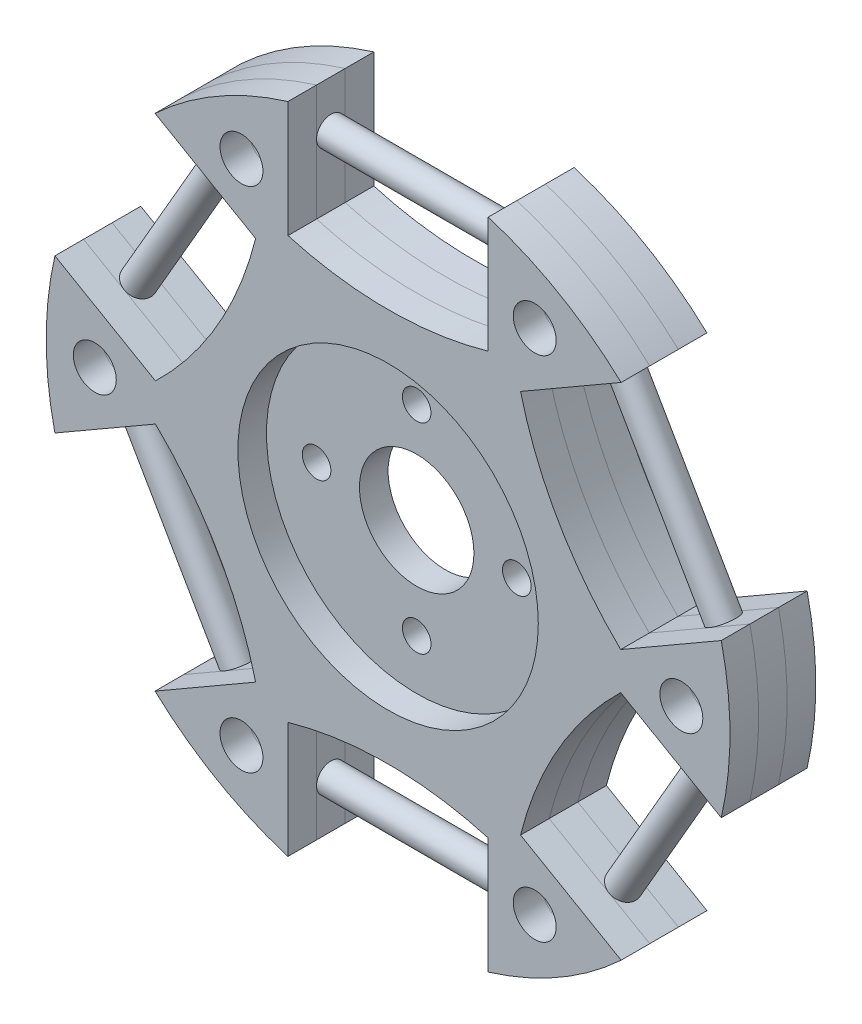
from build123d import *

# Parameters (mm, degrees)
SKETCH_1_R               = 25.4
SKETCH_1_R_2             = 10.5
EXTRUDE_1_DEPTH          = 2
SKETCH_2_R               = 25.4
SKETCH_2_R_2             = 4
EXTRUDE_2_DEPTH          = 2
SKETCH_3_R               = 25.4
SKETCH_3_R_2             = 10.5
EXTRUDE_3_DEPTH          = 2
CUT_EXTRUDE_1_DEPTH      = 20.5
SKETCH_5_R               = 1.5
CUT_EXTRUDE_2_DEPTH      = 20.5
SKETCH_6_R               = 1
EXTRUDE_4_DEPTH          = 14
PATTERN_CIRCULAR_1_COUNT = 6
SKETCH_7_R               = 1
CUT_EXTRUDE_3_DEPTH      = 14
SKETCH_8_R               = 33.9
SKETCH_8_R_2             = 23.9
CUT_EXTRUDE_1_2_DEPTH    = 10


with BuildPart() as part:
    # 草图1 → 凸台-拉伸1 (new body)
    with BuildSketch(Plane.XY):
        Circle(SKETCH_1_R)
        Circle(SKETCH_1_R_2, mode=Mode.SUBTRACT)
    extrude(amount=EXTRUDE_1_DEPTH)


with BuildPart() as body_2:
    # 草图2 → 凸台-拉伸2 (new body)
    with BuildSketch(Plane.XY.offset(2)):
        Circle(SKETCH_2_R)
        Circle(SKETCH_2_R_2, mode=Mode.SUBTRACT)
    extrude(amount=EXTRUDE_2_DEPTH)


with BuildPart() as body_3:
    # 草图3 → 凸台-拉伸3 (new body)
    with BuildSketch(Plane.XY.offset(4)):
        Circle(SKETCH_3_R)
        Circle(SKETCH_3_R_2, mode=Mode.SUBTRACT)
    extrude(amount=EXTRUDE_3_DEPTH)


with BuildPart() as cut_extrude_1_tool:
    # 草图4 → Cut-Extrude 1 (new body)
    with BuildSketch(Plane.XY.offset(6)):
        with BuildLine():
            Line((9.259682334, 13.428983857), (17.645212224, 18.270371796))
            ThreePointArc((17.645212224, 18.270371796), (21.997045256, 12.7), (24.645212224, 6.146016143))
            Line((24.645212224, 6.146016143), (16.259682334, 1.304628204))
            ThreePointArc((16.259682334, 1.304628204), (11.907849302, 6.875), (9.259682334, 13.428983857))
        make_face()
        with BuildLine():
            Line((7, 14.733612061), (7, 24.416387939))
            ThreePointArc((7, 24.416387939), (0, 25.4), (-7, 24.416387939))
            Line((-7, 24.416387939), (-7, 14.733612061))
            ThreePointArc((-7, 14.733612061), (0, 13.75), (7, 14.733612061))
        make_face()
        with BuildLine():
            Line((16.259682334, -1.304628204), (24.645212224, -6.146016143))
            ThreePointArc((24.645212224, -6.146016143), (21.997045256, -12.7), (17.645212224, -18.270371796))
            Line((17.645212224, -18.270371796), (9.259682334, -13.428983857))
            ThreePointArc((9.259682334, -13.428983857), (11.907849302, -6.875), (16.259682334, -1.304628204))
        make_face()
        with BuildLine():
            Line((7, -14.733612061), (7, -24.416387939))
            ThreePointArc((7, -24.416387939), (0, -25.4), (-7, -24.416387939))
            Line((-7, -24.416387939), (-7, -14.733612061))
            ThreePointArc((-7, -14.733612061), (0, -13.75), (7, -14.733612061))
        make_face()
        with BuildLine():
            Line((-9.259682334, -13.428983857), (-17.645212224, -18.270371796))
            ThreePointArc((-17.645212224, -18.270371796), (-21.997045256, -12.7), (-24.645212224, -6.146016143))
            Line((-24.645212224, -6.146016143), (-16.259682334, -1.304628204))
            ThreePointArc((-16.259682334, -1.304628204), (-11.907849302, -6.875), (-9.259682334, -13.428983857))
        make_face()
        with BuildLine():
            Line((-16.259682334, 1.304628204), (-24.645212224, 6.146016143))
            ThreePointArc((-24.645212224, 6.146016143), (-21.997045256, 12.7), (-17.645212224, 18.270371796))
            Line((-17.645212224, 18.270371796), (-9.259682334, 13.428983857))
            ThreePointArc((-9.259682334, 13.428983857), (-11.907849302, 6.875), (-16.259682334, 1.304628204))
        make_face()
    extrude(amount=-CUT_EXTRUDE_1_DEPTH)


with BuildPart() as part_1:
    add(part.part)

    # Cut-Extrude 1: cut by cut_extrude_1_tool
    add(cut_extrude_1_tool.part, mode=Mode.SUBTRACT)


with BuildPart() as body_2_1:
    add(body_2.part)

    # Cut-Extrude 1: cut by cut_extrude_1_tool
    add(cut_extrude_1_tool.part, mode=Mode.SUBTRACT)


with BuildPart() as body_3_1:
    add(body_3.part)

    # Cut-Extrude 1: cut by cut_extrude_1_tool
    add(cut_extrude_1_tool.part, mode=Mode.SUBTRACT)


with BuildPart() as cut_extrude_2_tool:
    # 草图5 → 切除-拉伸2 (new body)
    with BuildSketch(Plane.XY.offset(6)):
        with Locations((10.25, 17.753520778)):
            Circle(SKETCH_5_R)
        with Locations((20.5, 0)):
            Circle(SKETCH_5_R)
        with Locations((10.25, -17.753520778)):
            Circle(SKETCH_5_R)
        with Locations((-10.25, -17.753520778)):
            Circle(SKETCH_5_R)
        with Locations((-20.5, 0)):
            Circle(SKETCH_5_R)
        with Locations((-10.25, 17.753520778)):
            Circle(SKETCH_5_R)
    extrude(amount=-CUT_EXTRUDE_2_DEPTH)


with BuildPart() as part_2:
    add(part_1.part)

    # 切除-拉伸2: cut by cut_extrude_2_tool
    add(cut_extrude_2_tool.part, mode=Mode.SUBTRACT)


with BuildPart() as body_2_2:
    add(body_2_1.part)

    # 切除-拉伸2: cut by cut_extrude_2_tool
    add(cut_extrude_2_tool.part, mode=Mode.SUBTRACT)

    # 草图6 → 凸台-拉伸4 (add)
    with BuildSketch(Plane(origin=(-7, 0, 0), x_dir=(0, 0, -1), z_dir=(1, 0, 0))):
        with Locations((-3, 19.575)):
            Circle(SKETCH_6_R)
    extrude_4 = extrude(amount=EXTRUDE_4_DEPTH)

    # 阵列(圆周)1: 凸台-拉伸4 ×6 about axis
    pattern_circular_1_axis = Axis((0, 0, 6), (0, 0, 1))
    for i in range(1, PATTERN_CIRCULAR_1_COUNT):
        add(extrude_4.rotate(pattern_circular_1_axis, i * 360 / PATTERN_CIRCULAR_1_COUNT))

    # 草图7 → 切除-拉伸3 (cut)
    with BuildSketch(Plane.XY.offset(4)):
        with Locations((-7, 0)):
            Circle(SKETCH_7_R)
        with Locations((0, 7)):
            Circle(SKETCH_7_R)
        with Locations((7, 0)):
            Circle(SKETCH_7_R)
        with Locations((0, -7)):
            Circle(SKETCH_7_R)
    extrude(amount=-CUT_EXTRUDE_3_DEPTH, mode=Mode.SUBTRACT)


with BuildPart() as body_3_2:
    add(body_3_1.part)

    # 切除-拉伸2: cut by cut_extrude_2_tool
    add(cut_extrude_2_tool.part, mode=Mode.SUBTRACT)


with BuildPart() as cut_extrude_1_2_tool:
    # 草图8 → Cut-Extrude 1 2 (new body)
    with BuildSketch(Plane.XY.offset(6)):
        Circle(SKETCH_8_R)
        Circle(SKETCH_8_R_2, mode=Mode.SUBTRACT)
    extrude(amount=-CUT_EXTRUDE_1_2_DEPTH)


with BuildPart() as part_3:
    add(part_2.part)

    # Cut-Extrude 1 2: cut by cut_extrude_1_2_tool
    add(cut_extrude_1_2_tool.part, mode=Mode.SUBTRACT)


with BuildPart() as body_2_3:
    add(body_2_2.part)

    # Cut-Extrude 1 2: cut by cut_extrude_1_2_tool
    add(cut_extrude_1_2_tool.part, mode=Mode.SUBTRACT)


with BuildPart() as body_3_3:
    add(body_3_2.part)

    # Cut-Extrude 1 2: cut by cut_extrude_1_2_tool
    add(cut_extrude_1_2_tool.part, mode=Mode.SUBTRACT)


solid = Compound([part_3.part, body_2_3.part, body_3_3.part])
